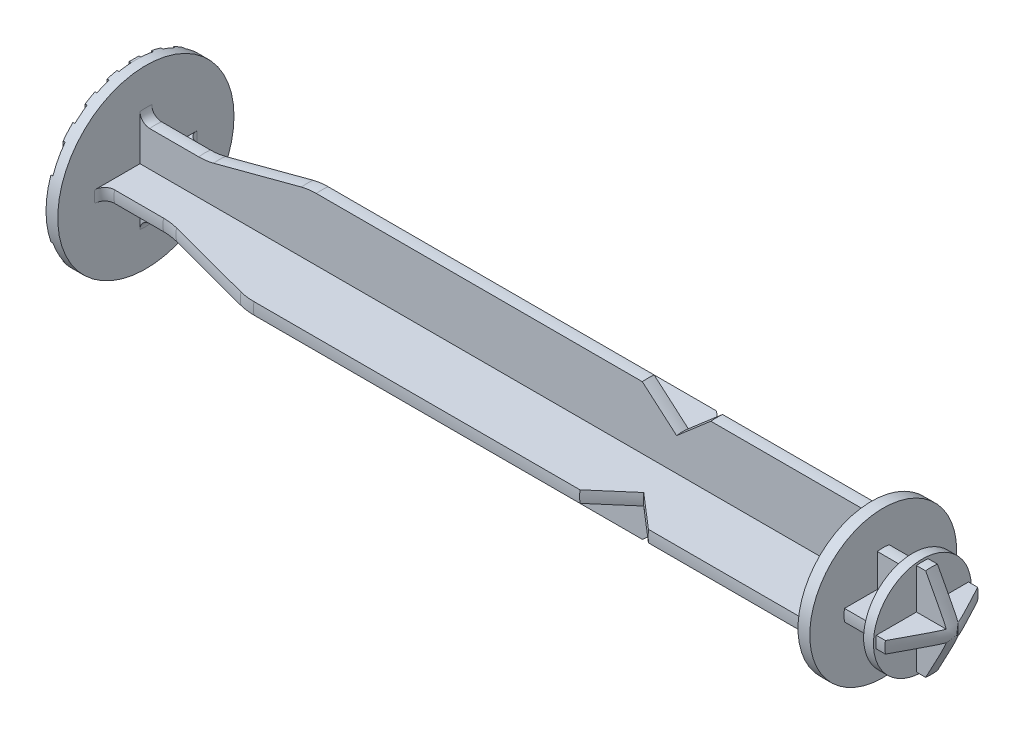
from build123d import *

# Parameters (mm, degrees)
SKETCH2_OUTSIDE_W   = 37.554
SKETCH2_OUTSIDE_H   = 37.554
CUT_EXTRUDE1_DEPTH  = 74.1
SKETCH3_OUTSIDE_W   = 37.554
SKETCH3_OUTSIDE_H   = 37.554
SKETCH3_OUTSIDE_W_2 = 1
SKETCH3_OUTSIDE_H_2 = 17.972200756
CUT_EXTRUDE2_DEPTH  = 0.2
SKETCH4_OUTSIDE_W   = 37.554
SKETCH4_OUTSIDE_H   = 37.554
CUT_EXTRUDE3_DEPTH  = 3
SKETCH5_OUTSIDE_W   = 37.554
SKETCH5_OUTSIDE_H   = 37.554
CUT_EXTRUDE4_DEPTH  = 3.5


with BuildPart() as part:
    # Sketch1 → Revolve1 (revolve)
    with BuildSketch(Plane.XY):
        with BuildLine():
            Line((0, 0), (0, 9))
            Line((0, 9), (1.2, 9))
            Line((1.2, 9), (1.2, 5.25))
            ThreePointArc((1.2, 5.25), (1.492893219, 4.542893219), (2.2, 4.25))
            Line((2.2, 4.25), (7.2, 4.25))
            ThreePointArc((7.2, 4.25), (7.970049199, 4.299619825), (8.72736183, 4.44765859))
            Line((8.72736183, 4.44765859), (17.67263817, 6.80234141))
            ThreePointArc((17.67263817, 6.80234141), (18.429950801, 6.950380175), (19.2, 7))
            Line((19.2, 7), (52.5, 7))
            Line((52.5, 7), (56, 4))
            Line((56, 4), (59.5, 7))
            Line((59.5, 7), (75.3, 7))
            Line((75.3, 7), (75.3, 7.5))
            Line((75.3, 7.5), (76.5, 7.5))
            Line((76.5, 7.5), (76.5, 4))
            Line((76.5, 4), (79.5, 4))
            Line((79.5, 4), (79.5, 5))
            Line((79.5, 5), (81.3, 5))
            Line((81.3, 5), (84, 0))
            Line((84, 0), (0, 0))
        make_face()
    revolve(axis=Axis((84, 0, 0), (-1, 0, 0)))

    # Sketch2 outside → Cut-Extrude1 (cut)
    with BuildSketch(Plane(origin=(1.2, 0, 0), x_dir=(0, 0, -1), z_dir=(1, 0, 0))):
        Rectangle(SKETCH2_OUTSIDE_W, SKETCH2_OUTSIDE_H)
        with BuildLine():
            Line((-0.6, 8.979977728), (-0.6, 0.6))
            Line((-0.6, 0.6), (-8.979977728, 0.6))
            ThreePointArc((-8.979977728, 0.6), (-9, 0), (-8.979977728, -0.6))
            Line((-8.979977728, -0.6), (-0.6, -0.6))
            Line((-0.6, -0.6), (-0.6, -8.979977728))
            ThreePointArc((-0.6, -8.979977728), (0, -9), (0.6, -8.979977728))
            Line((0.6, -8.979977728), (0.6, -0.6))
            Line((0.6, -0.6), (8.979977728, -0.6))
            ThreePointArc((8.979977728, -0.6), (9, 0), (8.979977728, 0.6))
            Line((8.979977728, 0.6), (0.6, 0.6))
            Line((0.6, 0.6), (0.6, 8.979977728))
            ThreePointArc((0.6, 8.979977728), (0, 9), (-0.6, 8.979977728))
        make_face(mode=Mode.SUBTRACT)
    extrude(amount=CUT_EXTRUDE1_DEPTH, mode=Mode.SUBTRACT)

    # Sketch3 outside → Cut-Extrude2 (cut)
    with BuildSketch(Plane.ZY):
        Rectangle(SKETCH3_OUTSIDE_W, SKETCH3_OUTSIDE_H)
        with Locations((2.25, 0)):
            Rectangle(SKETCH3_OUTSIDE_W_2, SKETCH3_OUTSIDE_H_2, mode=Mode.SUBTRACT)
        Rectangle(SKETCH3_OUTSIDE_W_2, SKETCH3_OUTSIDE_H_2, mode=Mode.SUBTRACT)
        with Locations((4.5, 0)):
            Rectangle(SKETCH3_OUTSIDE_W_2, SKETCH3_OUTSIDE_H_2, mode=Mode.SUBTRACT)
        with Locations((6.75, 0)):
            Rectangle(SKETCH3_OUTSIDE_W_2, SKETCH3_OUTSIDE_H_2, mode=Mode.SUBTRACT)
        with Locations((9, 0)):
            Rectangle(SKETCH3_OUTSIDE_W_2, SKETCH3_OUTSIDE_H_2, mode=Mode.SUBTRACT)
        with Locations((11.25, 0)):
            Rectangle(SKETCH3_OUTSIDE_W_2, SKETCH3_OUTSIDE_H_2, mode=Mode.SUBTRACT)
        with Locations((13.5, 0)):
            Rectangle(SKETCH3_OUTSIDE_W_2, SKETCH3_OUTSIDE_H_2, mode=Mode.SUBTRACT)
        with Locations((-2.25, 0)):
            Rectangle(SKETCH3_OUTSIDE_W_2, SKETCH3_OUTSIDE_H_2, mode=Mode.SUBTRACT)
        with Locations((-4.5, 0)):
            Rectangle(SKETCH3_OUTSIDE_W_2, SKETCH3_OUTSIDE_H_2, mode=Mode.SUBTRACT)
        with Locations((-6.75, 0)):
            Rectangle(SKETCH3_OUTSIDE_W_2, SKETCH3_OUTSIDE_H_2, mode=Mode.SUBTRACT)
        with Locations((-9, 0)):
            Rectangle(SKETCH3_OUTSIDE_W_2, SKETCH3_OUTSIDE_H_2, mode=Mode.SUBTRACT)
        with Locations((-11.25, 0)):
            Rectangle(SKETCH3_OUTSIDE_W_2, SKETCH3_OUTSIDE_H_2, mode=Mode.SUBTRACT)
        with Locations((-13.5, 0)):
            Rectangle(SKETCH3_OUTSIDE_W_2, SKETCH3_OUTSIDE_H_2, mode=Mode.SUBTRACT)
    extrude(amount=-CUT_EXTRUDE2_DEPTH, mode=Mode.SUBTRACT)

    # Sketch4 outside → Cut-Extrude3 (cut)
    with BuildSketch(Plane(origin=(76.5, 0, 0), x_dir=(0, 0, -1), z_dir=(1, 0, 0))):
        Rectangle(SKETCH4_OUTSIDE_W, SKETCH4_OUTSIDE_H)
        with BuildLine():
            Line((0.6, 0.6), (0.6, 8.979977728))
            ThreePointArc((0.6, 8.979977728), (0, 9), (-0.6, 8.979977728))
            Line((-0.6, 8.979977728), (-0.6, 0.6))
            Line((-0.6, 0.6), (-8.979977728, 0.6))
            ThreePointArc((-8.979977728, 0.6), (-9, 0), (-8.979977728, -0.6))
            Line((-8.979977728, -0.6), (-0.6, -0.6))
            Line((-0.6, -0.6), (-0.6, -8.979977728))
            ThreePointArc((-0.6, -8.979977728), (0, -9), (0.6, -8.979977728))
            Line((0.6, -8.979977728), (0.6, -0.6))
            Line((0.6, -0.6), (8.979977728, -0.6))
            ThreePointArc((8.979977728, -0.6), (9, 0), (8.979977728, 0.6))
            Line((8.979977728, 0.6), (0.6, 0.6))
        make_face(mode=Mode.SUBTRACT)
    extrude(amount=CUT_EXTRUDE3_DEPTH, mode=Mode.SUBTRACT)

    # Sketch5 outside → Cut-Extrude4 (cut)
    with BuildSketch(Plane(origin=(84, 0, 0), x_dir=(0, 0, -1), z_dir=(1, 0, 0))):
        Rectangle(SKETCH5_OUTSIDE_W, SKETCH5_OUTSIDE_H)
        with BuildLine():
            Line((0.6, 0.6), (0.6, 4.711952886))
            ThreePointArc((0.6, 4.711952886), (0, 4.75), (-0.6, 4.711952886))
            Line((-0.6, 4.711952886), (-0.6, 0.6))
            Line((-0.6, 0.6), (-4.711952886, 0.6))
            ThreePointArc((-4.711952886, 0.6), (-4.75, 0), (-4.711952886, -0.6))
            Line((-4.711952886, -0.6), (-0.6, -0.6))
            Line((-0.6, -0.6), (-0.6, -4.711952886))
            ThreePointArc((-0.6, -4.711952886), (0, -4.75), (0.6, -4.711952886))
            Line((0.6, -4.711952886), (0.6, -0.6))
            Line((0.6, -0.6), (4.711952886, -0.6))
            ThreePointArc((4.711952886, -0.6), (4.75, 0), (4.711952886, 0.6))
            Line((4.711952886, 0.6), (0.6, 0.6))
        make_face(mode=Mode.SUBTRACT)
    extrude(amount=-CUT_EXTRUDE4_DEPTH, mode=Mode.SUBTRACT)


solid = part.part
